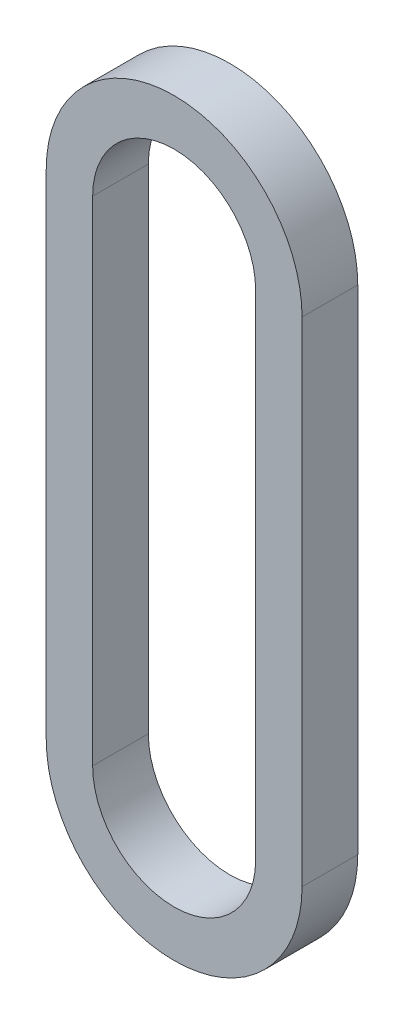
from build123d import *

# Parameters (mm, degrees)
BOSS_EXTRUDE1_DEPTH = 7.62


with BuildPart() as part:
    # Sketch1 → Boss-Extrude1 (new body)
    with BuildSketch(Plane.XY):
        with BuildLine():
            Line((-17.5006, 0), (-17.5006, 67.5))
            ThreePointArc((-17.5006, 67.5), (0, 85.0006), (17.5006, 67.5))
            Line((17.5006, 67.5), (17.5006, 0))
            ThreePointArc((17.5006, 0), (0, -17.5006), (-17.5006, 0))
        make_face()
        with BuildLine():
            Line((-11.1506, 0), (-11.1506, 67.5))
            ThreePointArc((-11.1506, 67.5), (0, 78.6506), (11.1506, 67.5))
            Line((11.1506, 67.5), (11.1506, 0))
            ThreePointArc((11.1506, 0), (0, -11.1506), (-11.1506, 0))
        make_face(mode=Mode.SUBTRACT)
    extrude(amount=BOSS_EXTRUDE1_DEPTH)


solid = part.part
